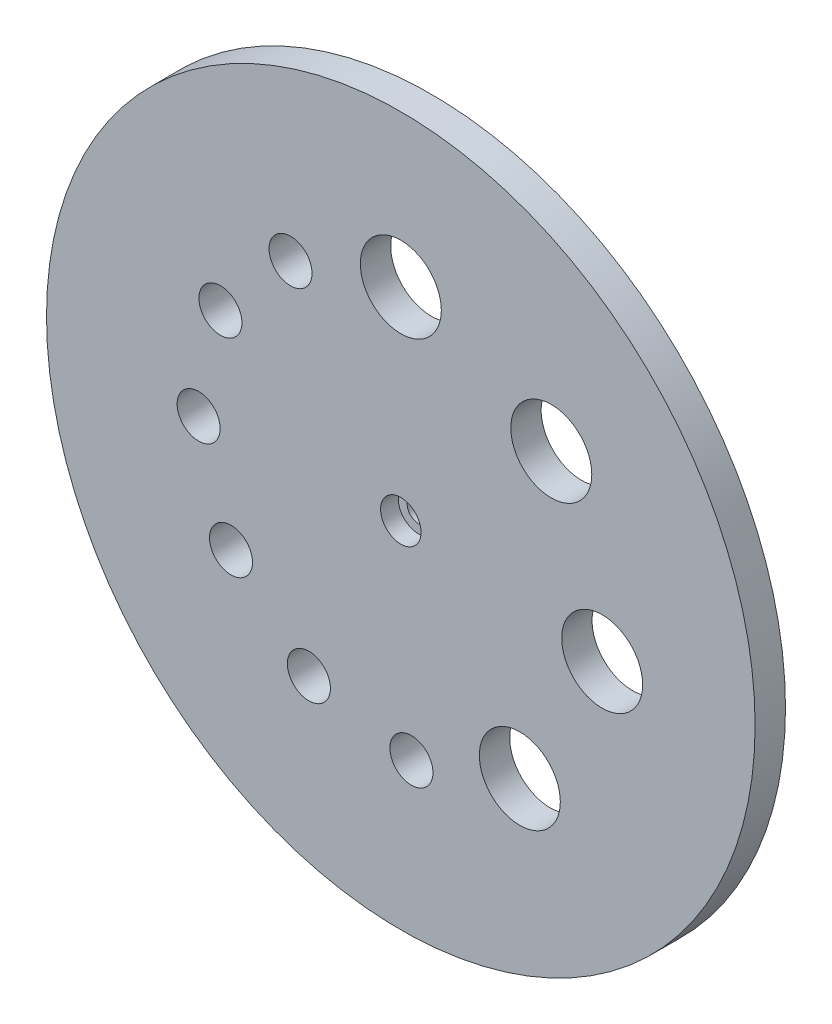
from build123d import *

# Parameters (mm, degrees)
SKETCH2_R                               = 140
BOSS_EXTRUDE1_DEPTH                     = 12
SKETCH3_R                               = 16
SKETCH3_R_2                             = 8.5
CUT_EXTRUDE1_DEPTH                      = 13
CBORE_FOR_M5_HEX_HEAD_BOLT1_D           = 9
CBORE_FOR_M5_HEX_HEAD_BOLT1_CBORE_D     = 16
CBORE_FOR_M5_HEX_HEAD_BOLT1_CBORE_DEPTH = 7


with BuildPart() as part:
    # Sketch2 → Boss-Extrude1 (new body)
    with BuildSketch(Plane.XY):
        Circle(SKETCH2_R)
    extrude(amount=BOSS_EXTRUDE1_DEPTH)

    # Sketch3 → Cut-Extrude1 (cut, through all)
    with BuildSketch(Plane.XY.offset(12)):
        with Locations((59.451586038, 53.530448509)):
            Circle(SKETCH3_R)
        with Locations((0, 80)):
            Circle(SKETCH3_R)
        with Locations((79.561751629, -8.362277061)):
            Circle(SKETCH3_R)
        with Locations((47.022820183, -64.72135955)):
            Circle(SKETCH3_R)
        with Locations((4.186876499, -79.89036278)):
            Circle(SKETCH3_R_2)
        with Locations((-36.319239979, -71.280521935)):
            Circle(SKETCH3_R_2)
        with Locations((-67.093645436, -43.571122801)):
            Circle(SKETCH3_R_2)
        with Locations((-79.89036278, -4.186876499)):
            Circle(SKETCH3_R_2)
        with Locations((-71.280521935, 36.319239979)):
            Circle(SKETCH3_R_2)
        with Locations((-43.571122801, 67.093645436)):
            Circle(SKETCH3_R_2)
    extrude(amount=-CUT_EXTRUDE1_DEPTH, mode=Mode.SUBTRACT)

    # CBORE for M5 Hex Head Bolt1 (through all)
    with Locations(Plane.XY.offset(12)):
        with Locations((0, 0)):
            CounterBoreHole(CBORE_FOR_M5_HEX_HEAD_BOLT1_D / 2, CBORE_FOR_M5_HEX_HEAD_BOLT1_CBORE_D / 2, CBORE_FOR_M5_HEX_HEAD_BOLT1_CBORE_DEPTH)


solid = part.part
